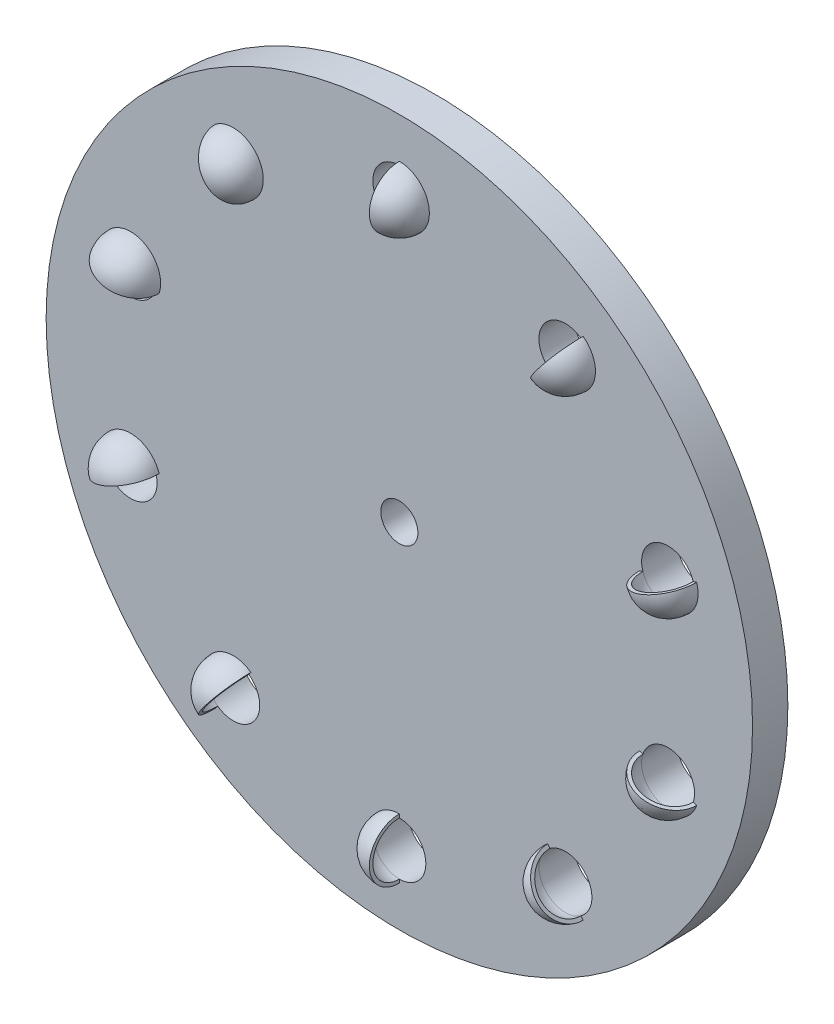
from build123d import *

# Parameters (mm, degrees)
SKETCH2_R           = 100
SKETCH2_R_2         = 5.25
SKETCH2_R_3         = 7.5
BOSS_EXTRUDE1_DEPTH = 10
REVOLVE6_ANGLE      = 90
CIRPATTERN3_COUNT   = 10


with BuildPart() as part:
    # Sketch2 → Boss-Extrude1 (new body)
    with BuildSketch(Plane.XY):
        Circle(SKETCH2_R)
        Circle(SKETCH2_R_2, mode=Mode.SUBTRACT)
        with Locations((0, 80)):
            Circle(SKETCH2_R_3, mode=Mode.SUBTRACT)
        with Locations((47.022820183, 64.72135955)):
            Circle(SKETCH2_R_3, mode=Mode.SUBTRACT)
        with Locations((76.084521304, 24.72135955)):
            Circle(SKETCH2_R_3, mode=Mode.SUBTRACT)
        with Locations((76.084521304, -24.72135955)):
            Circle(SKETCH2_R_3, mode=Mode.SUBTRACT)
        with Locations((47.022820183, -64.72135955)):
            Circle(SKETCH2_R_3, mode=Mode.SUBTRACT)
        with Locations((0, -80)):
            Circle(SKETCH2_R_3, mode=Mode.SUBTRACT)
        with Locations((-47.022820183, -64.72135955)):
            Circle(SKETCH2_R_3, mode=Mode.SUBTRACT)
        with Locations((-76.084521304, -24.72135955)):
            Circle(SKETCH2_R_3, mode=Mode.SUBTRACT)
        with Locations((-76.084521304, 24.72135955)):
            Circle(SKETCH2_R_3, mode=Mode.SUBTRACT)
        with Locations((-47.022820183, 64.72135955)):
            Circle(SKETCH2_R_3, mode=Mode.SUBTRACT)
    extrude(amount=BOSS_EXTRUDE1_DEPTH)

    # Sketch7 → Revolve6 (revolve)
    with BuildSketch(Plane.XY.offset(10)):
        with BuildLine():
            Line((0, -88.5), (0, -87.5))
            ThreePointArc((0, -87.5), (-7.5, -80), (0, -72.5))
            Line((0, -72.5), (0, -71.5))
            ThreePointArc((0, -71.5), (-8.5, -80), (0, -88.5))
        make_face()
    revolve6 = revolve(axis=Axis((0, -88.5, 10), (0, 1, 0)), revolution_arc=REVOLVE6_ANGLE)

    # CirPattern3: Revolve6 ×10 about axis
    cirpattern3_axis = Axis((0, 0, 0), (0, 0, 1))
    for i in range(1, CIRPATTERN3_COUNT):
        add(revolve6.rotate(cirpattern3_axis, i * 360 / CIRPATTERN3_COUNT))


solid = part.part
